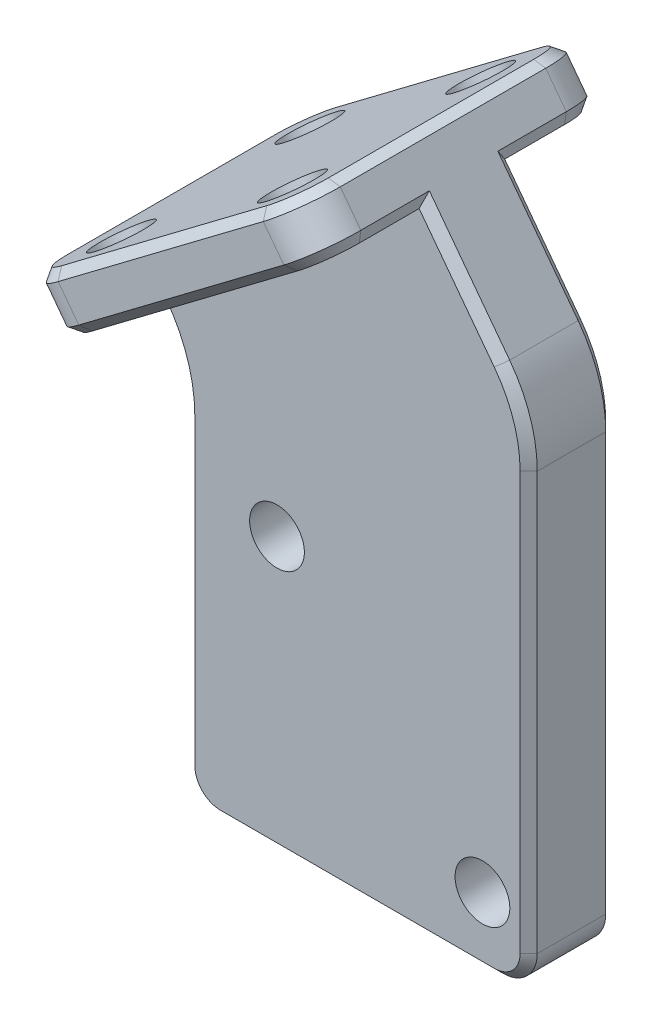
from build123d import *

# Parameters (mm, degrees)
SKETCH_1_R      = 1.6
SKETCH_1_R_2    = 1.6000000000000019
EXTRUDE_1_DEPTH = 5
SKETCH_2_R      = 1.6000000000000016
SKETCH_2_R_2    = 1.6000000000000125
SKETCH_2_R_3    = 1.6000000000000019
EXTRUDE_2_DEPTH = 3
CHAMFER_1_SIZE  = 0.5


with BuildPart() as part:
    # 草图1 → 凸台-拉伸1 (new body)
    with BuildSketch(Plane.XY):
        with BuildLine():
            Line((0, 2.000000000000014), (0, 19.705362587260357))
            ThreePointArc((0, 19.705362587260357), (-0.4134107583503983, 22.243799838501072), (-1.610915919621628, 24.519882772476706))
            Line((-1.610915919621628, 24.519882772476706), (-1.9727102009459283, 25))
            Line((-1.9727102009459283, 25), (13.999999999999998, 37.036300463040874))
            Line((13.999999999999998, 37.036300463040874), (18.389084080378368, 31.211789162518105))
            ThreePointArc((18.389084080378368, 31.211789162518105), (19.586589241649598, 28.93570622854247), (19.999999999999993, 26.397268977301756))
            Line((19.999999999999993, 26.397268977301756), (20, 2.0000000000000147))
            ThreePointArc((20, 2.0000000000000147), (19.414213562373096, 0.5857864376269051), (17.999999999999986, 0))
            Line((17.999999999999986, 0), (2.000000000000014, 0))
            ThreePointArc((2.000000000000014, 0), (0.5857864376269044, 0.5857864376269049), (0, 2.000000000000014))
        make_face()
        with Locations((5.299999999999996, 16)):
            Circle(SKETCH_1_R, mode=Mode.SUBTRACT)
        with Locations((17.3, 3.999999999999999)):
            Circle(SKETCH_1_R_2, mode=Mode.SUBTRACT)
    extrude(amount=EXTRUDE_1_DEPTH)

    # 草图2 → 凸台-拉伸2 (add)
    with BuildSketch(Plane(origin=(-12.730249987910918, 16.89361232439068, 0), x_dir=(0.7986355100472964, 0.6018150231520436, 0), z_dir=(-0.6018150231520436, 0.7986355100472964, 0))):
        with BuildLine():
            Line((30.96989916129314, -11.000000000000002), (15.969899161293144, -11.000000000000002))
            ThreePointArc((15.969899161293144, -11.000000000000002), (14.202132208326773, -10.267766952966369), (13.469899161293144, -8.499999999999998))
            Line((13.469899161293144, -8.499999999999998), (13.469899161293144, 3.500000000000003))
            ThreePointArc((13.469899161293144, 3.500000000000003), (14.202132208326775, 5.267766952966372), (15.969899161293144, 6.000000000000004))
            Line((15.969899161293144, 6.000000000000004), (30.96989916129314, 6.000000000000004))
            ThreePointArc((30.96989916129314, 6.000000000000004), (32.737666114259504, 5.26776695296637), (33.469899161293135, 3.5000000000000036))
            Line((33.469899161293135, 3.5000000000000036), (33.469899161293135, -8.499999999999998))
            ThreePointArc((33.469899161293135, -8.499999999999998), (32.73766611425951, -10.267766952966369), (30.96989916129314, -11.000000000000002))
        make_face()
        with Locations((17.21989916129313, 3.0000000000000004)):
            Circle(SKETCH_2_R, mode=Mode.SUBTRACT)
        with Locations((29.71989916129313, 3.0000000000000018)):
            Circle(SKETCH_2_R_2, mode=Mode.SUBTRACT)
        with Locations((29.71989916129313, -7.999999999999998)):
            Circle(SKETCH_2_R_2, mode=Mode.SUBTRACT)
        with Locations((17.21989916129313, -8)):
            Circle(SKETCH_2_R_3, mode=Mode.SUBTRACT)
    extrude(amount=EXTRUDE_2_DEPTH)

    # 倒角1
    chamfer_1_edges = [part.edges().sort_by_distance(p)[0] for p in [
        (-0.4134107583503974, 22.243799838501072, 5),
        (19.999999999999996, 14.198634488650885, 0),
        (19.414213562373096, 0.5857864376269046, 0),
        (10, 0, 0),
        (0.5857864376269049, 0.5857864376269046, 0),
        (0, 10.852681293630186, 0),
        (-0.4134107583503974, 22.243799838501072, 0),
        (-1.7918130602837783, 24.759941386238353, 0),
        (0, 10.852681293630186, 5),
        (0.5857864376269049, 0.5857864376269046, 5),
        (10, 0, 5),
        (19.414213562373096, 0.5857864376269046, 5),
        (19.999999999999996, 14.198634488650885, 5),
        (19.586589241649598, 28.93570622854247, 5),
        (16.194542040189184, 34.12404481277949, 5),
        (-3.19336795741086, 27.83657537829513, 10.267766952966369),
        (4.208199830070912, 33.41405676166233, 11.000000000000002),
        (11.609767617552686, 38.99153814502953, 10.26776695296637),
        (12.194554930543871, 39.43220699318276, 2.4999999999999973),
        (11.609767617552682, 38.99153814502952, -5.26776695296637),
        (4.208199830070912, 33.41405676166233, -6.000000000000004),
        (-3.1933679574108584, 27.83657537829513, -5.267766952966372),
        (-3.778155270402049, 27.395906530141897, 2.4999999999999973),
        (-1.3879228879547298, 25.440668848153244, 10.267766952966369),
        (6.013644899527042, 31.018150231520444, 11.000000000000002),
        (13.415212687008816, 36.59563161488764, 10.26776695296637),
        (14.000000000000002, 37.036300463040874, 6.75),
        (14.000000000000002, 37.036300463040874, -1.7500000000000018),
        (13.415212687008813, 36.59563161488764, -5.26776695296637),
        (6.013644899527042, 31.018150231520444, -6.000000000000004),
        (-1.387922887954728, 25.440668848153244, -5.267766952966372),
        (-1.9727102009459188, 25.000000000000007, -1.7500000000000018),
        (-1.9727102009459188, 25.000000000000007, 6.749999999999999),
        (-1.7918130602837783, 24.759941386238353, 5),
        (16.194542040189184, 34.12404481277949, 0),
        (19.586589241649598, 28.93570622854247, 0),
    ]]
    chamfer(chamfer_1_edges, length=CHAMFER_1_SIZE)


solid = part.part
